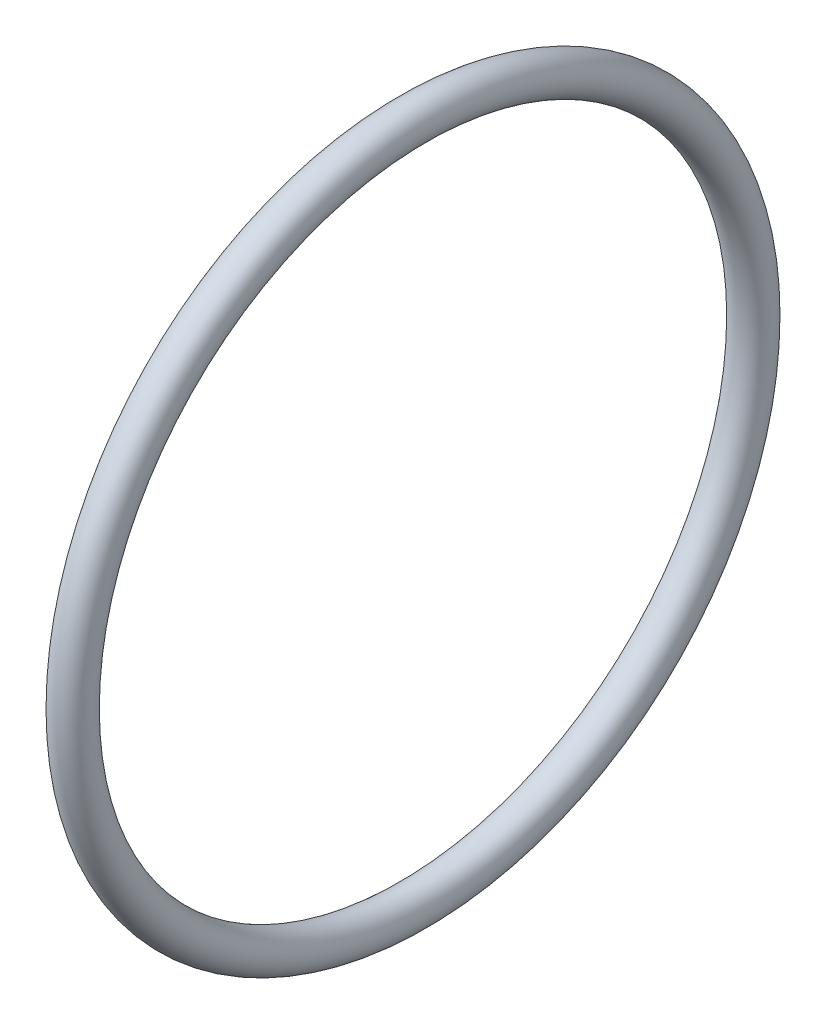
from build123d import *

# Parameters (mm, degrees)
ESBO_O1_R = 1.5


with BuildPart() as part:
    # Esboço1 → Revolução1 (revolve)
    with BuildSketch(Plane.XY):
        with Locations((0, 27.075)):
            Circle(ESBO_O1_R)
    revolve(axis=Axis((0, 0, 0), (-1, 0, 0)))


solid = part.part
